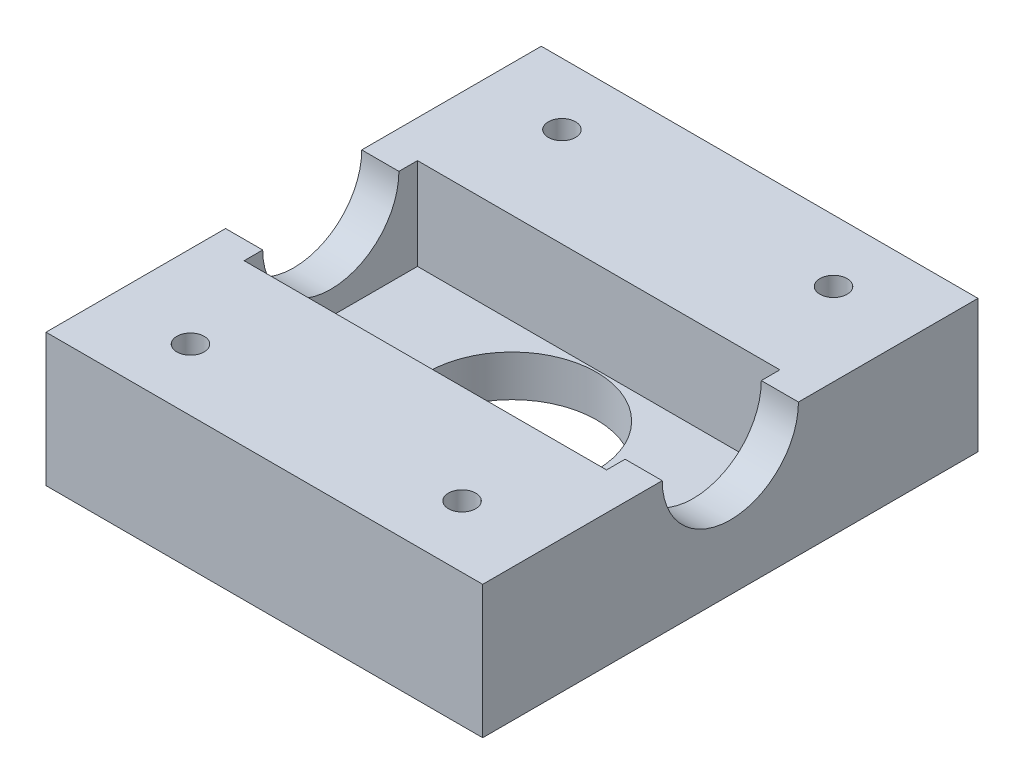
from build123d import *

# Parameters (mm, degrees)
SKETCH1_W             = 52.9
SKETCH1_H             = 30
SKETCH1_R             = 10.25
BOSS_EXTRUDE1_DEPTH   = 5
SKETCH3_W             = 52.9
SKETCH3_H             = 30
SKETCH3_W_2           = 43.9
SKETCH3_H_2           = 21
BOSS_EXTRUDE2_DEPTH   = 11.1
SKETCH4_R             = 8.25
CUT_EXTRUDE1_DEPTH    = 53.9
SKETCH5_W             = 52.9
SKETCH5_H             = 5
BOSS_EXTRUDE3_DEPTH   = 15
SKETCH6_W             = 52.9
SKETCH6_H             = 5
BOSS_EXTRUDE4_DEPTH   = 15
SKETCH7_W             = 52.9
SKETCH7_H             = 15
BOSS_EXTRUDE5_DEPTH   = 11.1
M4_TAPPED_HOLE1_D     = 3.3
M4_TAPPED_HOLE1_DEPTH = 9.108579979
M4_TAPPED_HOLE1_TIP   = 0.991420021


with BuildPart() as part:
    # Sketch1 → Boss-Extrude1 (new body)
    with BuildSketch(Plane(origin=(0, 0, 0), x_dir=(1, 0, 0), z_dir=(0, 1, 0))):
        Rectangle(SKETCH1_W, SKETCH1_H)
        Circle(SKETCH1_R, mode=Mode.SUBTRACT)
    extrude(amount=BOSS_EXTRUDE1_DEPTH)

    # Sketch3 → Boss-Extrude2 (add)
    with BuildSketch(Plane(origin=(0, 5, 0), x_dir=(1, 0, 0), z_dir=(0, 1, 0))):
        Rectangle(SKETCH3_W, SKETCH3_H)
        Rectangle(SKETCH3_W_2, SKETCH3_H_2, mode=Mode.SUBTRACT)
    extrude(amount=BOSS_EXTRUDE2_DEPTH)

    # Sketch4 → Cut-Extrude1 (cut, through all)
    with BuildSketch(Plane(origin=(26.45, 0, 0), x_dir=(0, 0, -1), z_dir=(1, 0, 0))):
        with Locations((0, 16.1)):
            Circle(SKETCH4_R)
    extrude(amount=-CUT_EXTRUDE1_DEPTH, mode=Mode.SUBTRACT)

    # Sketch5 → Boss-Extrude3 (add)
    with BuildSketch(Plane.XY.offset(15)):
        with Locations((0, 13.6)):
            Rectangle(SKETCH5_W, SKETCH5_H)
    extrude(amount=BOSS_EXTRUDE3_DEPTH)

    # Sketch6 → Boss-Extrude4 (add)
    with BuildSketch(Plane(origin=(0, 0, -15), x_dir=(-1, 0, 0), z_dir=(0, 0, -1))):
        with Locations((0, 13.6)):
            Rectangle(SKETCH6_W, SKETCH6_H)
    extrude(amount=BOSS_EXTRUDE4_DEPTH)

    # Sketch7 → Boss-Extrude5 (add)
    with BuildSketch(Plane.XZ.offset(-11.1)):
        with Locations((0, 22.5)):
            Rectangle(SKETCH7_W, SKETCH7_H)
        with Locations((0, -22.5)):
            Rectangle(SKETCH7_W, SKETCH7_H)
    extrude(amount=BOSS_EXTRUDE5_DEPTH)

    # M4 Tapped Hole1
    with Locations(Plane(origin=(0, 16.1, 0), x_dir=(1, 0, 0), z_dir=(0, 1, 0))):
        with Locations((-16.45, -22.5), (16.45, -22.5), (16.45, 22.5), (-16.45, 22.5)):
            Hole(M4_TAPPED_HOLE1_D / 2, depth=M4_TAPPED_HOLE1_DEPTH)
            with Locations((0, 0, -(M4_TAPPED_HOLE1_DEPTH + M4_TAPPED_HOLE1_TIP / 2))):  # 118° drill point
                Cone(0, M4_TAPPED_HOLE1_D / 2, M4_TAPPED_HOLE1_TIP, mode=Mode.SUBTRACT)


solid = part.part
